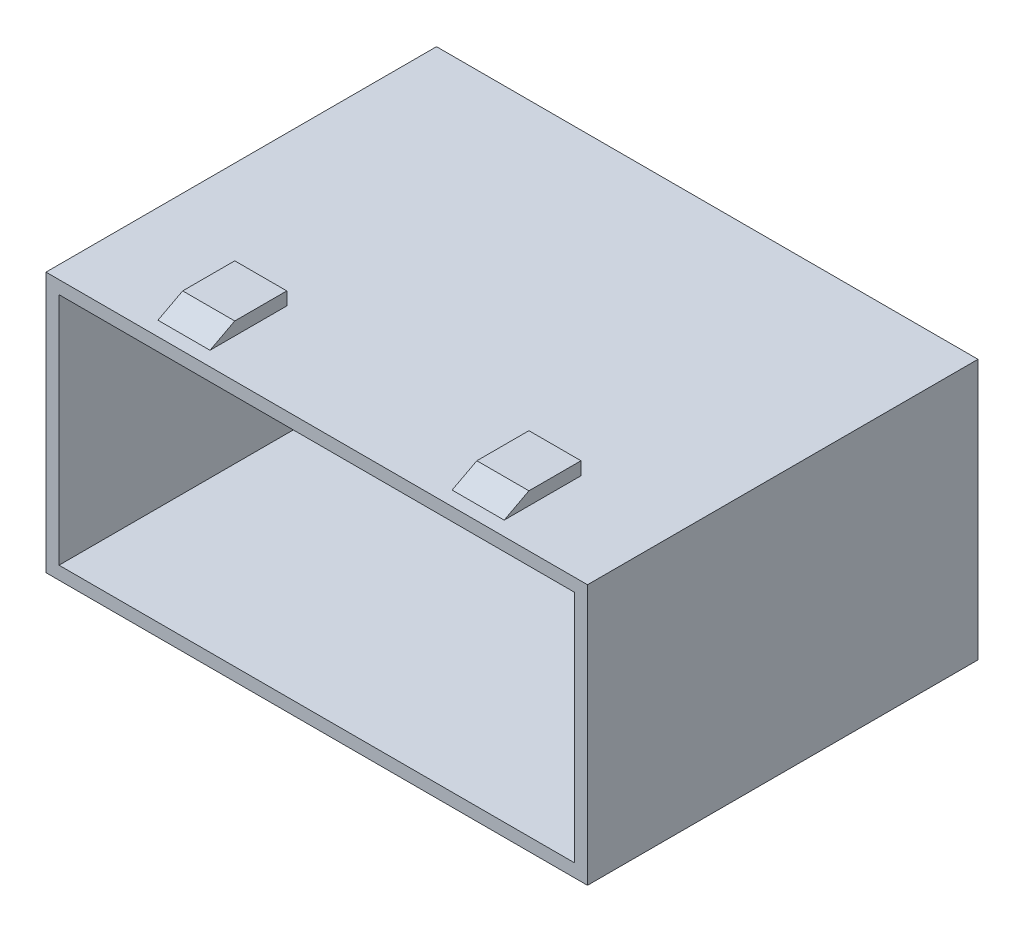
from build123d import *

# Parameters (mm, degrees)
SKETCH1_W           = 41.6
SKETCH1_H           = 20
SKETCH1_W_2         = 39.6
SKETCH1_H_2         = 18
BOSS_EXTRUDE2_DEPTH = 10
SKETCH2_W           = 4
SKETCH2_H           = 10
BOSS_EXTRUDE3_DEPTH = 1
SKETCH3_W           = 3
SKETCH3_H           = 1
CUT_EXTRUDE1_DEPTH  = 27
SKETCH4_W           = 4
SKETCH4_H           = 10
BOSS_EXTRUDE4_DEPTH = 1
SKETCH5_W           = 3
SKETCH5_H           = 1
CUT_EXTRUDE2_DEPTH  = 27
SKETCH6_W           = 41.6
SKETCH6_H           = 20
SKETCH6_W_2         = 39.6
SKETCH6_H_2         = 18
BOSS_EXTRUDE6_DEPTH = 19
SKETCH7_W           = 41.6
SKETCH7_H           = 20
BOSS_EXTRUDE7_DEPTH = 1


with BuildPart() as part:
    # Sketch1 → Boss-Extrude2 (new body)
    with BuildSketch(Plane.XY):
        Rectangle(SKETCH1_W, SKETCH1_H)
        Rectangle(SKETCH1_W_2, SKETCH1_H_2, mode=Mode.SUBTRACT)
    extrude(amount=BOSS_EXTRUDE2_DEPTH)

    # Sketch2 → Boss-Extrude3 (add)
    with BuildSketch(Plane.XZ.offset(10)):
        with Locations((-11.3, 5)):
            Rectangle(SKETCH2_W, SKETCH2_H)
        with Locations((11.3, 5)):
            Rectangle(SKETCH2_W, SKETCH2_H)
    extrude(amount=BOSS_EXTRUDE3_DEPTH)

    # Sketch3 → Cut-Extrude1 (cut)
    with BuildSketch(Plane.ZY.offset(13.3)):
        Polygon((8.900149248, -10), (7, -11), (10, -11), (10, -10), align=None)
        with Locations((1.5, -10.5)):
            Rectangle(SKETCH3_W, SKETCH3_H)
    extrude(amount=-CUT_EXTRUDE1_DEPTH, mode=Mode.SUBTRACT)

    # Sketch4 → Boss-Extrude4 (add)
    with BuildSketch(Plane(origin=(0, 10, 0), x_dir=(1, 0, 0), z_dir=(0, 1, 0))):
        with Locations((11.3, -5)):
            Rectangle(SKETCH4_W, SKETCH4_H)
        with Locations((-11.3, -5)):
            Rectangle(SKETCH4_W, SKETCH4_H)
    extrude(amount=BOSS_EXTRUDE4_DEPTH)

    # Sketch5 → Cut-Extrude2 (cut)
    with BuildSketch(Plane(origin=(13.3, 0, 0), x_dir=(0, 0, -1), z_dir=(1, 0, 0))):
        Polygon((-7, 11), (-10, 11), (-10, 10), (-8.900149248, 10), align=None)
        with Locations((-1.5, 10.5)):
            Rectangle(SKETCH5_W, SKETCH5_H)
    extrude(amount=-CUT_EXTRUDE2_DEPTH, mode=Mode.SUBTRACT)

    # Sketch6 → Boss-Extrude6 (add)
    with BuildSketch(Plane(origin=(0, 0, 0), x_dir=(-1, 0, 0), z_dir=(0, 0, -1))):
        Rectangle(SKETCH6_W, SKETCH6_H)
        Rectangle(SKETCH6_W_2, SKETCH6_H_2, mode=Mode.SUBTRACT)
    extrude(amount=BOSS_EXTRUDE6_DEPTH)

    # Sketch7 → Boss-Extrude7 (add)
    with BuildSketch(Plane(origin=(0, 0, -19), x_dir=(-1, 0, 0), z_dir=(0, 0, -1))):
        Rectangle(SKETCH7_W, SKETCH7_H)
    extrude(amount=BOSS_EXTRUDE7_DEPTH)


solid = part.part
